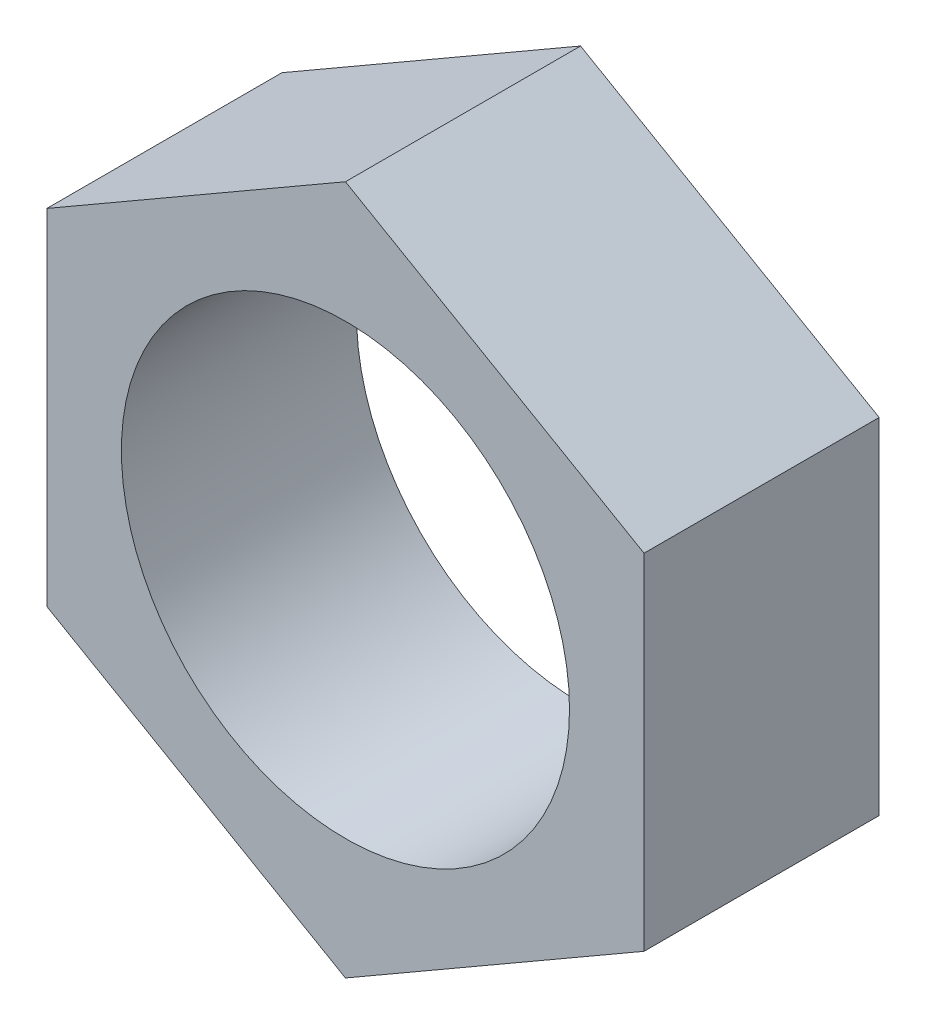
from build123d import *

# Parameters (mm, degrees)
CROQUIS1_R              = 4.765
SALIENTE_EXTRUIR1_DEPTH = 5


with BuildPart() as part:
    # Croquis1 → Saliente-Extruir1 (new body)
    with BuildSketch(Plane.XY):
        Polygon((-6.35, -3.666174209), (0, -7.332348419), (6.35, -3.666174209), (6.35, 3.666174209), (0, 7.332348419), (-6.35, 3.666174209), align=None)
        Circle(CROQUIS1_R, mode=Mode.SUBTRACT)
    extrude(amount=SALIENTE_EXTRUIR1_DEPTH)


solid = part.part
